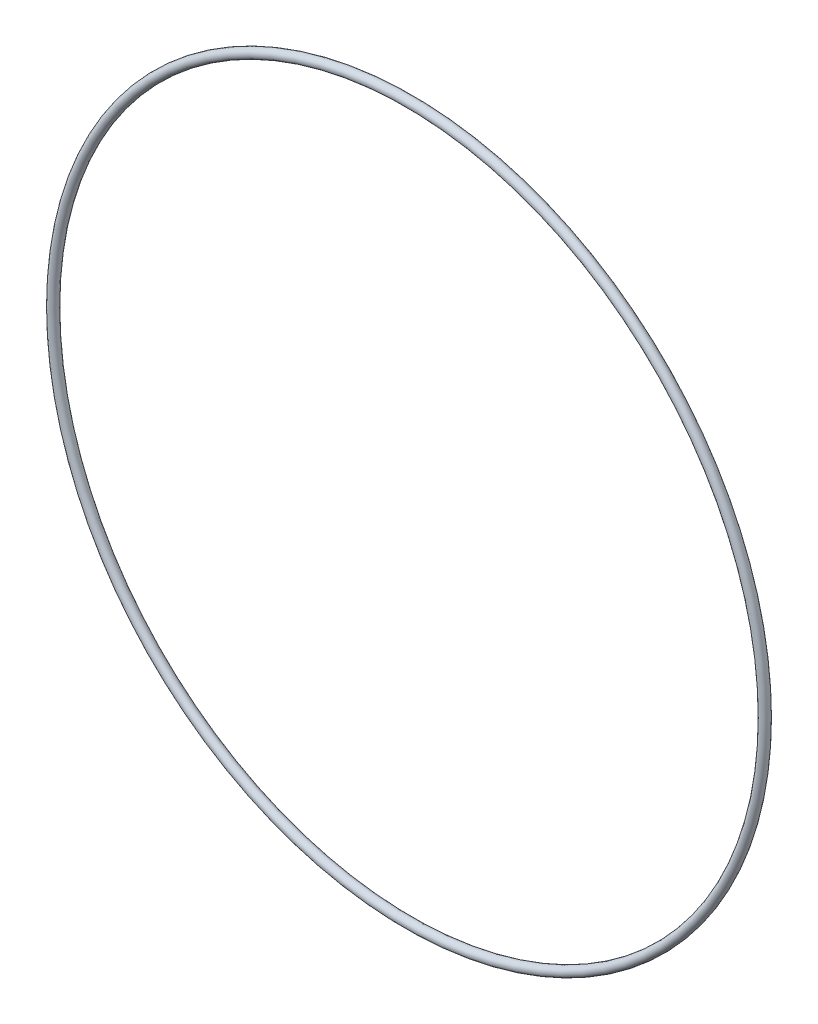
from build123d import *

# Parameters (mm, degrees)
SKETCH1_R = 0.889


with BuildPart() as part:
    # Sketch1 → Revolve1 (revolve)
    with BuildSketch(Plane(origin=(0, 0, 0), x_dir=(0, -1, 0), z_dir=(1, 0, 0))):
        with Locations((67.4243, 0)):
            Circle(SKETCH1_R)
    revolve(axis=Axis((0, 0, 0.889), (0, 0, -1)))


solid = part.part
